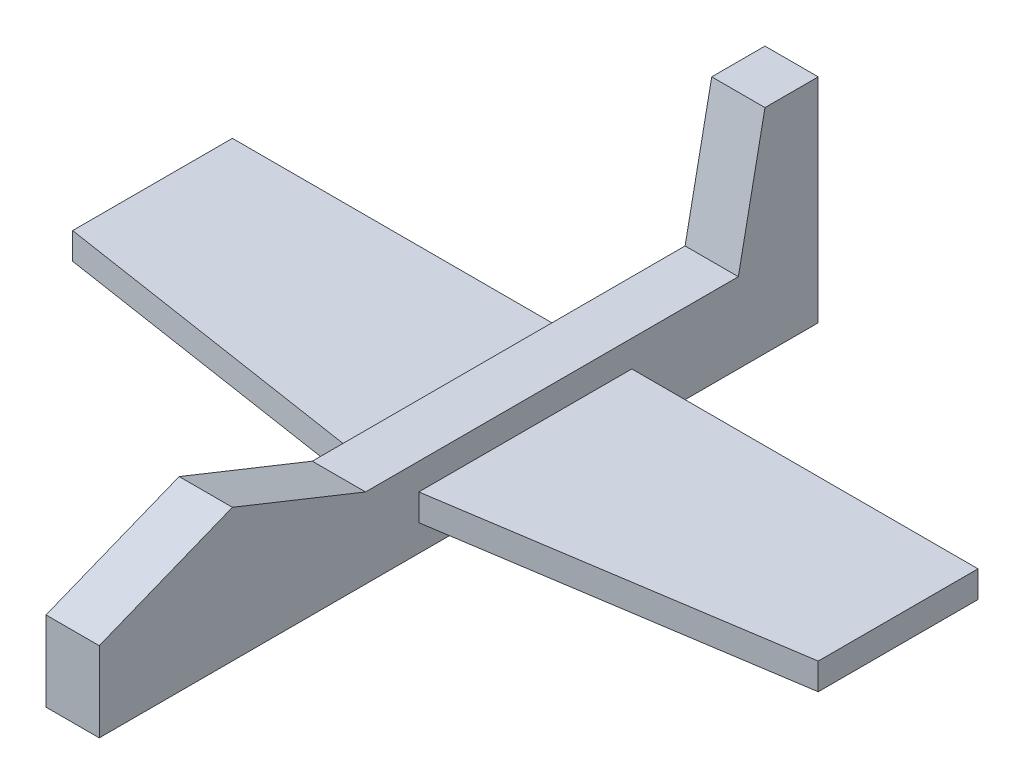
from build123d import *

# Parameters (mm, degrees)
BOSS_EXTRUDE1_DEPTH      = 5
BOSS_EXTRUDE1_DEPTH_BACK = 5
BOSS_EXTRUDE2_DEPTH      = 5


with BuildPart() as part:
    # Sketch1 → Boss-Extrude1 (new body, two sides)
    with BuildSketch(Plane(origin=(0, 0, 0), x_dir=(0, 0, -1), z_dir=(1, 0, 0))) as boss_extrude1_sk:
        Polygon((0, 0), (0, 15), (25, 25), (50, 15), (120, 15), (125, 40), (135, 40), (135, 0), align=None)
    extrude(amount=BOSS_EXTRUDE1_DEPTH)
    extrude(boss_extrude1_sk.sketch, amount=-BOSS_EXTRUDE1_DEPTH_BACK)

    # Sketch2 → Boss-Extrude2 (add)
    with BuildSketch(Plane(origin=(0, 5, 0), x_dir=(1, 0, 0), z_dir=(0, 1, 0))):
        Polygon((5, 60), (70, 70), (70, 100), (5, 100), align=None)
    boss_extrude2 = extrude(amount=BOSS_EXTRUDE2_DEPTH)

    # Mirror1: Boss-Extrude2 across plane
    add(boss_extrude2.mirror(Plane(origin=(0, 0, 0), x_dir=(0, 0, 1), z_dir=(1, 0, 0))))


solid = part.part
